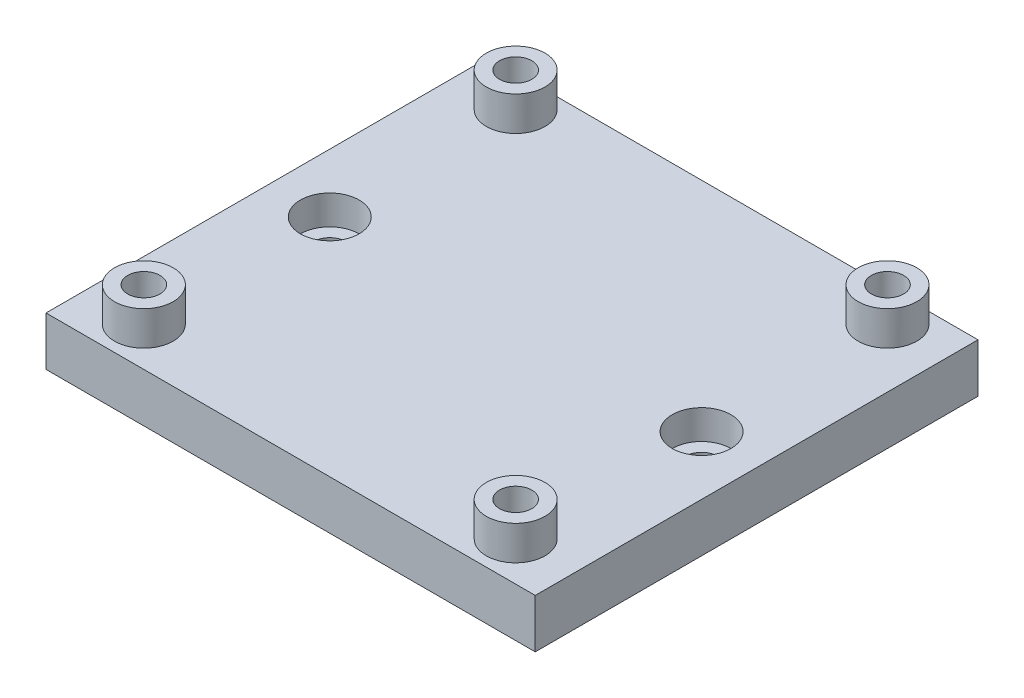
from build123d import *

# Parameters (mm, degrees)
SKETCH2_W           = 50
SKETCH2_H           = 55
SKETCH2_R           = 1.65
BOSS_EXTRUDE2_DEPTH = 6
SKETCH4_R           = 3
SKETCH4_R_2         = 1.65
BOSS_EXTRUDE3_DEPTH = 3.5
SKETCH5_R           = 3
CUT_EXTRUDE2_DEPTH  = 3
SKETCH6_W           = 50
SKETCH6_H           = 3.75
SKETCH6_H_2         = 6
CUT_EXTRUDE3_DEPTH  = 10
SKETCH7_W           = 50
SKETCH7_H           = 45.25
CUT_EXTRUDE4_DEPTH  = 1


with BuildPart() as part:
    # Sketch2 → Boss-Extrude2 (new body)
    with BuildSketch(Plane(origin=(0, 0, 0), x_dir=(1, 0, 0), z_dir=(0, 1, 0))):
        with Locations((25, 27.5)):
            Rectangle(SKETCH2_W, SKETCH2_H)
        with Locations((6, 10)):
            Circle(SKETCH2_R, mode=Mode.SUBTRACT)
        with Locations((44, 10)):
            Circle(SKETCH2_R, mode=Mode.SUBTRACT)
        with Locations((44, 48)):
            Circle(SKETCH2_R, mode=Mode.SUBTRACT)
        with Locations((6, 48)):
            Circle(SKETCH2_R, mode=Mode.SUBTRACT)
        with Locations((6, 29)):
            Circle(SKETCH2_R, mode=Mode.SUBTRACT)
        with Locations((44, 29)):
            Circle(SKETCH2_R, mode=Mode.SUBTRACT)
    extrude(amount=BOSS_EXTRUDE2_DEPTH)

    # Sketch4 → Boss-Extrude3 (add)
    with BuildSketch(Plane(origin=(0, 6, 0), x_dir=(1, 0, 0), z_dir=(0, 1, 0))):
        with Locations((6, 10)):
            Circle(SKETCH4_R)
        with Locations((6, 10)):
            Circle(SKETCH4_R_2, mode=Mode.SUBTRACT)
        with Locations((44, 10)):
            Circle(SKETCH4_R)
        with Locations((44, 10)):
            Circle(SKETCH4_R_2, mode=Mode.SUBTRACT)
        with Locations((6, 48)):
            Circle(SKETCH4_R)
        with Locations((6, 48)):
            Circle(SKETCH4_R_2, mode=Mode.SUBTRACT)
        with Locations((44, 48)):
            Circle(SKETCH4_R)
        with Locations((44, 48)):
            Circle(SKETCH4_R_2, mode=Mode.SUBTRACT)
    extrude(amount=BOSS_EXTRUDE3_DEPTH)

    # Sketch5 → Cut-Extrude2 (cut)
    with BuildSketch(Plane(origin=(0, 6, 0), x_dir=(1, 0, 0), z_dir=(0, 1, 0))):
        with Locations((6, 29)):
            Circle(SKETCH5_R)
        with Locations((44, 29)):
            Circle(SKETCH5_R)
    extrude(amount=-CUT_EXTRUDE2_DEPTH, mode=Mode.SUBTRACT)

    # Sketch6 → Cut-Extrude3 (cut)
    with BuildSketch(Plane(origin=(0, 6, 0), x_dir=(1, 0, 0), z_dir=(0, 1, 0))):
        with Locations((25, 53.125)):
            Rectangle(SKETCH6_W, SKETCH6_H)
        with Locations((25, 3)):
            Rectangle(SKETCH6_W, SKETCH6_H_2)
    extrude(amount=-CUT_EXTRUDE3_DEPTH, mode=Mode.SUBTRACT)

    # Sketch7 → Cut-Extrude4 (cut)
    with BuildSketch(Plane.XZ):
        with Locations((25, -28.625)):
            Rectangle(SKETCH7_W, SKETCH7_H)
    extrude(amount=-CUT_EXTRUDE4_DEPTH, mode=Mode.SUBTRACT)


solid = part.part
